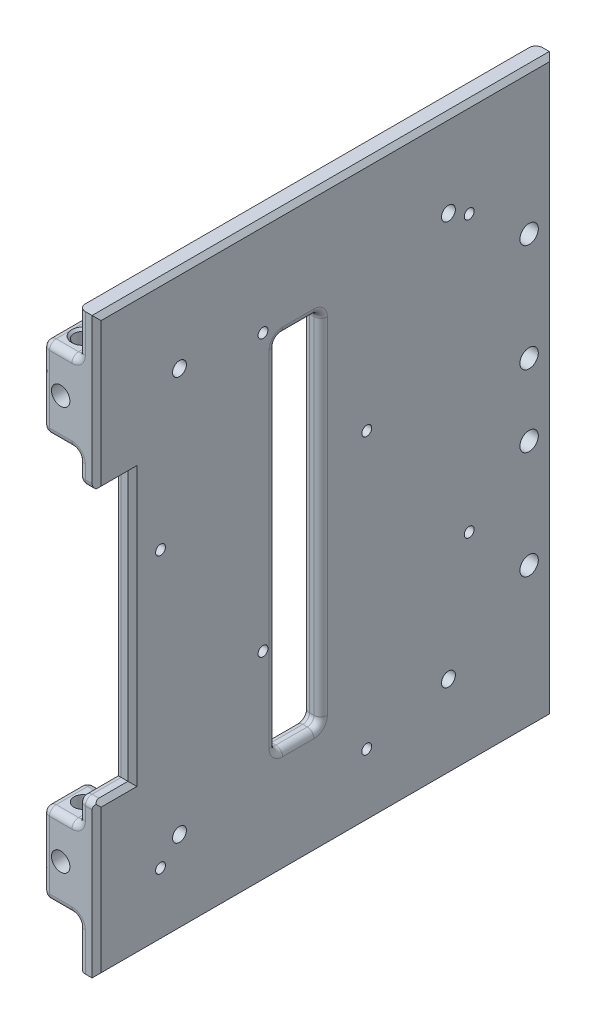
from build123d import *

# Parameters (mm, degrees)
SKETCH1_W           = 102
SKETCH1_H           = 108
BOSS_EXTRUDE1_DEPTH = 8
SKETCH2_W           = 102
SKETCH2_H           = 128
BOSS_EXTRUDE2_DEPTH = 4
SKETCH3_W           = 102
SKETCH3_H           = 72
CUT_EXTRUDE1_DEPTH  = 8
SKETCH5_W           = 82
SKETCH5_H           = 108
CUT_EXTRUDE3_DEPTH  = 8
SKETCH6_W           = 8
SKETCH6_H           = 60
CUT_EXTRUDE4_DEPTH  = 4
SKETCH14_W          = 10
SKETCH14_H          = 8
BOSS_EXTRUDE3_DEPTH = 8
SKETCH4_R           = 2.025
CUT_EXTRUDE2_DEPTH  = 119
SKETCH7_R           = 2.05
SKETCH7_W           = 10
SKETCH7_H           = 80
CUT_EXTRUDE5_DEPTH  = 12
SKETCH11_R          = 2.05
CUT_EXTRUDE8_DEPTH  = 3.5
CHAMFER1_SIZE       = 1
FILLET2_R           = 1.5
CHAMFER2_SIZE       = 0.5
FILLET3_R           = 1.5
SKETCH8_R           = 1.1
SKETCH8_R_2         = 1.55
CUT_EXTRUDE6_DEPTH  = 4


with BuildPart() as part:
    # Sketch1 → Boss-Extrude1 (new body)
    with BuildSketch(Plane(origin=(0, 0, 0), x_dir=(0, 0, -1), z_dir=(1, 0, 0))):
        Rectangle(SKETCH1_W, SKETCH1_H)
    extrude(amount=BOSS_EXTRUDE1_DEPTH)

    # Sketch2 → Boss-Extrude2 (add)
    with BuildSketch(Plane(origin=(8, 0, 0), x_dir=(0, 0, -1), z_dir=(1, 0, 0))):
        Rectangle(SKETCH2_W, SKETCH2_H)
    extrude(amount=BOSS_EXTRUDE2_DEPTH)

    # Sketch3 → Cut-Extrude1 (cut)
    with BuildSketch(Plane.ZY):
        Rectangle(SKETCH3_W, SKETCH3_H)
    extrude(amount=-CUT_EXTRUDE1_DEPTH, mode=Mode.SUBTRACT)

    # Sketch5 → Cut-Extrude3 (cut)
    with BuildSketch(Plane.ZY):
        Rectangle(SKETCH5_W, SKETCH5_H)
    extrude(amount=-CUT_EXTRUDE3_DEPTH, mode=Mode.SUBTRACT)

    # Sketch6 → Cut-Extrude4 (cut)
    with BuildSketch(Plane(origin=(12, 0, 0), x_dir=(0, 0, -1), z_dir=(1, 0, 0))):
        with Locations((-47, 0)):
            Rectangle(SKETCH6_W, SKETCH6_H)
    extrude(amount=-CUT_EXTRUDE4_DEPTH, mode=Mode.SUBTRACT)

    # Sketch14 → Boss-Extrude3 (add)
    with BuildSketch(Plane.ZY.offset(-8)):
        with Locations((-46, 32)):
            Rectangle(SKETCH14_W, SKETCH14_H)
        with Locations((-46, -32)):
            Rectangle(SKETCH14_W, SKETCH14_H)
    extrude(amount=BOSS_EXTRUDE3_DEPTH)

    # Sketch4 → Cut-Extrude2 (cut, through all)
    with BuildSketch(Plane.XZ.offset(54)):
        with Locations((4, 46)):
            Circle(SKETCH4_R)
        with Locations((4, -46)):
            Circle(SKETCH4_R)
    extrude(amount=-CUT_EXTRUDE2_DEPTH, mode=Mode.SUBTRACT)

    # Sketch7 → Cut-Extrude5 (cut)
    with BuildSketch(Plane(origin=(12, 0, 0), x_dir=(0, 0, -1), z_dir=(1, 0, 0))):
        with Locations((45.5, -32)):
            Circle(SKETCH7_R)
        with Locations((45.5, 32)):
            Circle(SKETCH7_R)
        with Locations((45.5, 8)):
            Circle(SKETCH7_R)
        with Locations((45.5, -8)):
            Circle(SKETCH7_R)
        with Locations((-6, 0)):
            Rectangle(SKETCH7_W, SKETCH7_H)
    extrude(amount=-CUT_EXTRUDE5_DEPTH, mode=Mode.SUBTRACT)

    # Sketch11 → Cut-Extrude8 (cut)
    with BuildSketch(Plane.XY.offset(51)):
        with Locations((4, 45)):
            Circle(SKETCH11_R)
        with Locations((4, -45)):
            Circle(SKETCH11_R)
    extrude(amount=-CUT_EXTRUDE8_DEPTH, mode=Mode.SUBTRACT)

    # Chamfer1
    chamfer1_edges = [part.edges().sort_by_distance(p)[0] for p in [
        (12, 0, -51),
        (12, 64, 0),
        (12, 47, 51),
        (12, -64, 0),
        (12, -47, 51),
        (12, 0, 43),
        (12, 30, 47),
        (12, -30, 47),
    ]]
    chamfer(chamfer1_edges, length=CHAMFER1_SIZE)

    # Fillet2
    fillet2_edges = [part.edges().sort_by_distance(p)[0] for p in [
        (8, 0, 11),
        (10, -40, 11),
        (8, 40, 6),
        (10, 40, 11),
        (8, 0, 1),
        (10, 40, 1),
        (8, -40, 6),
        (10, -40, 1),
        (12, 0, 11),
        (12, -40, 6),
        (12, 0, 1),
        (12, 40, 6),
        (8, 0, 43),
        (8, -30, 47),
        (8, 30, 47),
    ]]
    fillet(fillet2_edges, radius=FILLET2_R)

    # Chamfer2
    chamfer2_edges = [part.edges().sort_by_distance(p)[0] for p in [
        (1.975, 54, 46),
        (1.975, -54, 46),
        (1.975, 54, -46),
        (1.975, -54, -46),
    ]]
    chamfer(chamfer2_edges, length=CHAMFER2_SIZE)

    # Fillet3
    fillet3_edges = [part.edges().sort_by_distance(p)[0] for p in [
        (4, -28, -51),
        (0, -28, -46),
        (4, -28, -41),
        (8, -28, -46),
        (8, -59, -51),
        (8, 59, -51),
        (8, 59, 51),
        (8, -59, 51),
        (8, 54, -46),
        (10.25, -30, 51),
        (8.439339828, -30.439339828, 51),
        (8, 33.75, 51),
        (10.25, 30, 51),
        (8.439339828, 30.439339828, 51),
        (0, -45, 51),
        (0, 41, -51),
        (0, 36, 46),
        (8, 36, 46),
        (4, -36, 51),
        (8, -33.75, 51),
        (4, 36, 51),
        (0, -36, 46),
        (8, -36, 46),
        (4, -36, 41),
        (8, 54, 46),
        (0, 54, -46),
        (8, -54, -46),
        (0, -54, -46),
        (0, 54, 46),
        (0, -41, -51),
        (0, 45, 41),
        (0, 41, -41),
        (0, -41, -41),
        (0, -45, 41),
        (8, 41, -41),
        (0, -54, 46),
        (8, -41, -41),
        (4, -54, -41),
        (4, 36, 41),
        (8, 45, 41),
        (4, 54, 41),
        (8, -45, 41),
        (4, 54, -41),
        (4, -54, 41),
        (0, 45, 51),
        (4, 54, 51),
        (4, 54, -51),
        (4, -54, -51),
        (4, -54, 51),
        (8, -54, 46),
        (8, 0, -51),
        (0, 28, -46),
        (4, 28, -51),
        (8, 28, -46),
        (4, 28, -41),
    ]]
    fillet(fillet3_edges, radius=FILLET3_R)

    # Sketch8 → Cut-Extrude6 (cut)
    with BuildSketch(Plane(origin=(12, 0, 0), x_dir=(0, 0, -1), z_dir=(1, 0, 0))):
        with Locations((-36.724141202, -49.393152746)):
            Circle(SKETCH8_R)
        with Locations((-13.864141202, -18.913152746)):
            Circle(SKETCH8_R)
        with Locations((-36.724141202, 12.086847254)):
            Circle(SKETCH8_R)
        with Locations((-13.864141202, 42.566847254)):
            Circle(SKETCH8_R)
        with Locations((9.275858798, -49.393152746)):
            Circle(SKETCH8_R)
        with Locations((32.135858798, -18.913152746)):
            Circle(SKETCH8_R)
        with Locations((9.275858798, 12.086847254)):
            Circle(SKETCH8_R)
        with Locations((32.135858798, 42.566847254)):
            Circle(SKETCH8_R)
        with Locations((-32.5, -45)):
            Circle(SKETCH8_R_2)
        with Locations((-32.5, 45)):
            Circle(SKETCH8_R_2)
        with Locations((27.5, -45)):
            Circle(SKETCH8_R_2)
        with Locations((27.5, 45)):
            Circle(SKETCH8_R_2)
    extrude(amount=-CUT_EXTRUDE6_DEPTH, mode=Mode.SUBTRACT)


solid = part.part
